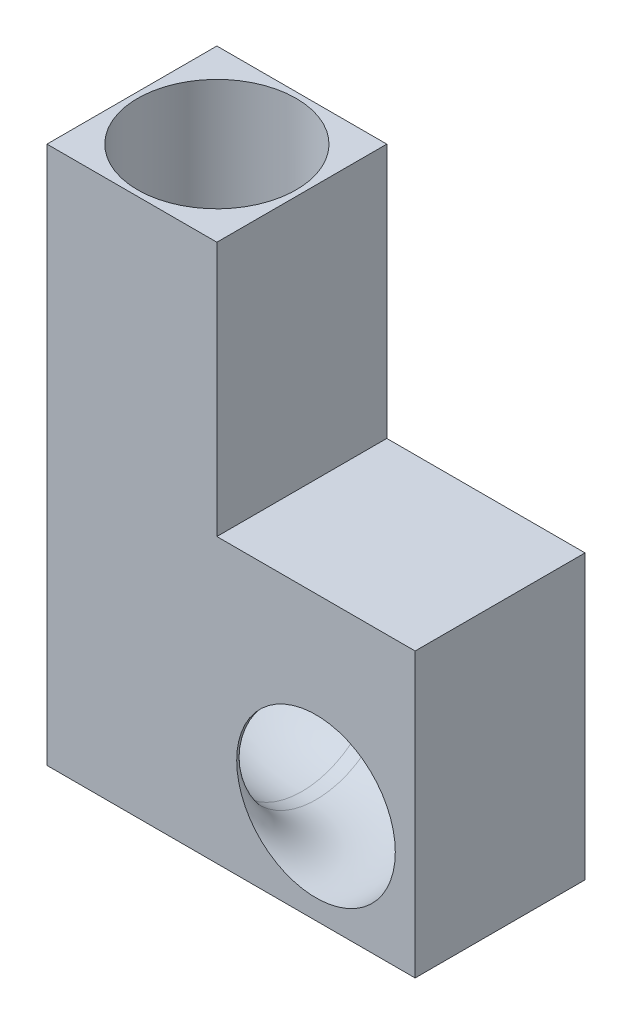
from build123d import *

# Parameters (mm, degrees)
BOSS_EXTRUDE1_DEPTH = 76.2
SKETCH2_R           = 35.56


with BuildPart() as part:
    # Sketch1 → Boss-Extrude1 (new body)
    with BuildSketch(Plane.XY):
        Polygon((0, 241.3), (0, 0), (165.1, 0), (165.1, 127), (76.2, 127), (76.2, 241.3), align=None)
    extrude(amount=BOSS_EXTRUDE1_DEPTH)

    # Cut-Sweep1: sweep along a curve in space
    with BuildLine() as cut_sweep1_path:
        Line((38.1, 241.3, 38.1), (38.1, 82.55, 38.1))
        ThreePointArc((38.1, 82.55, 38.1), (49.259231637, 55.609231637, 38.1), (76.2, 44.45, 38.1))
        Line((76.2, 44.45, 38.1), (82.55, 44.45, 38.1))
        ThreePointArc((120.65, 44.45, 76.2), (109.490768363, 44.45, 49.259231637), (82.55, 44.45, 38.1))
    # Sketch2 → Cut-Sweep1 (sweep, cut)
    with BuildSketch(Plane(origin=(0, 241.3, 0), x_dir=(1, 0, 0), z_dir=(0, 1, 0))):
        with Locations((38.1, -38.1)):
            Circle(SKETCH2_R)
    sweep(path=cut_sweep1_path.line, mode=Mode.SUBTRACT)


solid = part.part
